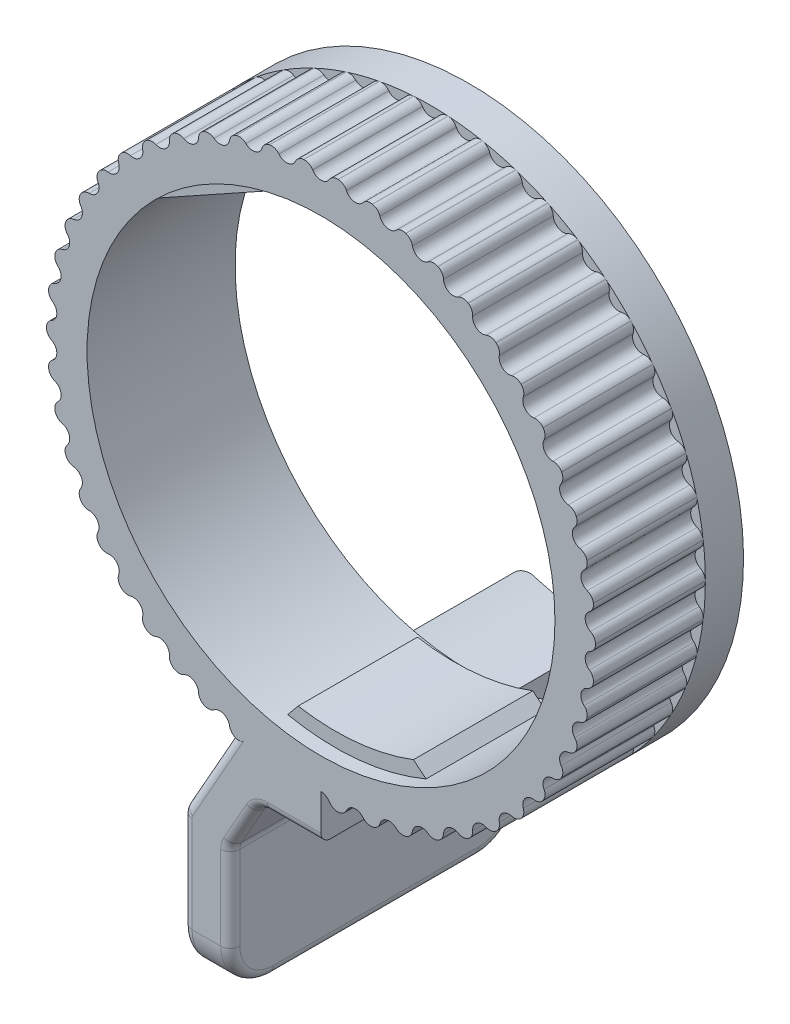
from build123d import *

# Parameters (mm, degrees)
SKETCH1_R           = 14.605
SKETCH1_R_2         = 12.446
BASE_EXTRUDE_DEPTH  = 3.937
BOSS_EXTRUDE3_DEPTH = 3.175
BOSS_EXTRUDE6_DEPTH = 3.175
CUT_EXTRUDE1_DEPTH  = 5.842
CIRPATTERN1_COUNT   = 50
BOSS_EXTRUDE4_DEPTH = 7.874
BOSS_EXTRUDE5_DEPTH = 7.62
FILLET1_R           = 2.286
FILLET2_R           = 0.762
FILLET5_R           = 0.508


with BuildPart() as part:
    # Sketch1 → Base-Extrude (new body, symmetric)
    with BuildSketch(Plane.XY):
        Circle(SKETCH1_R)
        Circle(SKETCH1_R_2, mode=Mode.SUBTRACT)
    extrude(amount=BASE_EXTRUDE_DEPTH, both=True)

    # Sketch5 → Boss-Extrude3 (add, symmetric)
    with BuildSketch(Plane.XY):
        with BuildLine():
            Line((-2.032, 12.279002077), (-9.357769774, 8.205794346))
            ThreePointArc((-9.357769774, 8.205794346), (-6.048096327, 10.87765815), (-2.032, 12.279002077))
        make_face()
        with BuildLine():
            Line((2.032, 12.279002077), (9.357769774, 8.205794346))
            ThreePointArc((9.357769774, 8.205794346), (6.048096327, 10.87765815), (2.032, 12.279002077))
        make_face()
    extrude(amount=BOSS_EXTRUDE3_DEPTH, both=True)

    # Sketch9 → Boss-Extrude6 (add, symmetric)
    with BuildSketch(Plane.XY):
        with BuildLine():
            Line((-1.978968483, -11.515187352), (-2.531078122, -12.185916442))
            ThreePointArc((-2.531078122, -12.185916442), (1.201663301, -12.387853781), (4.826, -11.472255227))
            Line((4.826, -11.472255227), (4.155270909, -10.920145588))
            ThreePointArc((4.155270909, -10.920145588), (1.128092078, -11.629413754), (-1.978968483, -11.515187352))
        make_face()
    extrude(amount=BOSS_EXTRUDE6_DEPTH, both=True)

    # Sketch2 → Cut-Extrude1 (cut)
    with BuildSketch(Plane.XY.offset(3.937)):
        with BuildLine():
            ThreePointArc((-0.444619656, 14.333998429), (0, 14.0843), (0.444619656, 14.333998429))
            ThreePointArc((0.444619656, 14.333998429), (0.643572333, 14.520075683), (0.910048801, 14.576619505))
            ThreePointArc((0.910048801, 14.576619505), (0, 14.605), (-0.910048801, 14.576619505))
            ThreePointArc((-0.910048801, 14.576619505), (-0.643572333, 14.520075683), (-0.444619656, 14.333998429))
        make_face()
    cut_extrude1 = extrude(amount=-CUT_EXTRUDE1_DEPTH, mode=Mode.SUBTRACT)

    # CirPattern1: Cut-Extrude1 ×50 about axis
    cirpattern1_axis = Axis((0, 0, 0), (0, 0, 1))
    for i in range(1, CIRPATTERN1_COUNT):
        add(cut_extrude1.rotate(cirpattern1_axis, i * 360 / CIRPATTERN1_COUNT), mode=Mode.SUBTRACT)

    # Sketch6 → Boss-Extrude4 (add, through all)
    with BuildSketch(Plane(origin=(0, 0, -3.937), x_dir=(-1, 0, 0), z_dir=(0, 0, -1))):
        with BuildLine():
            Line((0, -12.446), (0, -16.51))
            Line((0, -16.51), (3.302, -16.51))
            Line((3.302, -16.51), (4.826, -19.209472627))
            Line((4.826, -19.209472627), (4.826, -26.162))
            Line((4.826, -26.162), (7.366, -26.162))
            Line((7.366, -26.162), (7.366, -18.542))
            Line((7.366, -18.542), (3.620595612, -11.907737124))
            ThreePointArc((3.620595612, -11.907737124), (1.830193945, -12.310698848), (0, -12.446))
        make_face()
    extrude(amount=-BOSS_EXTRUDE4_DEPTH)

    # Sketch7 → Boss-Extrude5 (add)
    with BuildSketch(Plane(origin=(0, 0, -3.937), x_dir=(-1, 0, 0), z_dir=(0, 0, -1))):
        with BuildLine():
            Line((0, -14.605), (0, -16.51))
            Line((0, -16.51), (3.302, -16.51))
            Line((3.302, -16.51), (4.826, -19.209472627))
            Line((4.826, -19.209472627), (4.826, -26.162))
            Line((4.826, -26.162), (7.366, -26.162))
            Line((7.366, -26.162), (7.366, -18.542))
            Line((7.366, -18.542), (4.70397567, -13.826736343))
            ThreePointArc((4.70397567, -13.826736343), (2.383961064, -14.409120537), (0, -14.605))
        make_face()
    extrude(amount=BOSS_EXTRUDE5_DEPTH)

    # Fillet1
    fillet1_edges = [part.edges().sort_by_distance(p)[0] for p in [
        (-6.096, -26.162, 3.937),
        (-6.096, -26.162, -11.557),
    ]]
    fillet(fillet1_edges, radius=FILLET1_R)

    # Fillet2
    fillet2_edges = [part.edges().sort_by_distance(p)[0] for p in [
        (-7.366, -18.542, -3.81),
        (-4.826, -19.209472627, -3.81),
        (-3.302, -16.51, -3.81),
    ]]
    fillet(fillet2_edges, radius=FILLET2_R)

    # Fillet5
    fillet5_edges = [part.edges().sort_by_distance(p)[0] for p in [
        (-1.428571624, -16.51, 3.937),
        (-1.428571624, -16.51, -11.557),
        (-7.366, -21.309120894, -11.557),
        (-7.366, -26.162, -3.81),
        (-7.366, -21.309120894, 3.937),
        (-7.366, -25.492446102, 3.267446102),
        (-7.366, -25.492446102, -10.887446102),
        (-4.826, -26.162, -3.81),
        (-4.826, -25.492446102, 3.267446102),
        (-4.826, -25.492446102, -10.887446102),
        (-4.124128786, -17.966242883, -11.557),
        (-4.124128786, -17.966242883, 3.937),
        (-4.826, -21.642857208, -11.557),
        (-4.826, -21.642857208, 3.937),
        (-5.985766416, -16.097181903, -11.557),
        (-7.340978479, -18.548575268, -11.557),
        (-5.977136488, -16.081895648, 3.937),
        (-7.340978479, -18.548575268, 3.937),
        (-3.241322818, -16.61393461, -11.557),
        (-3.241322818, -16.61393461, 3.937),
        (-4.800978479, -19.216047895, -11.557),
        (-4.800978479, -19.216047895, 3.937),
    ]]
    fillet(fillet5_edges, radius=FILLET5_R)


solid = part.part
